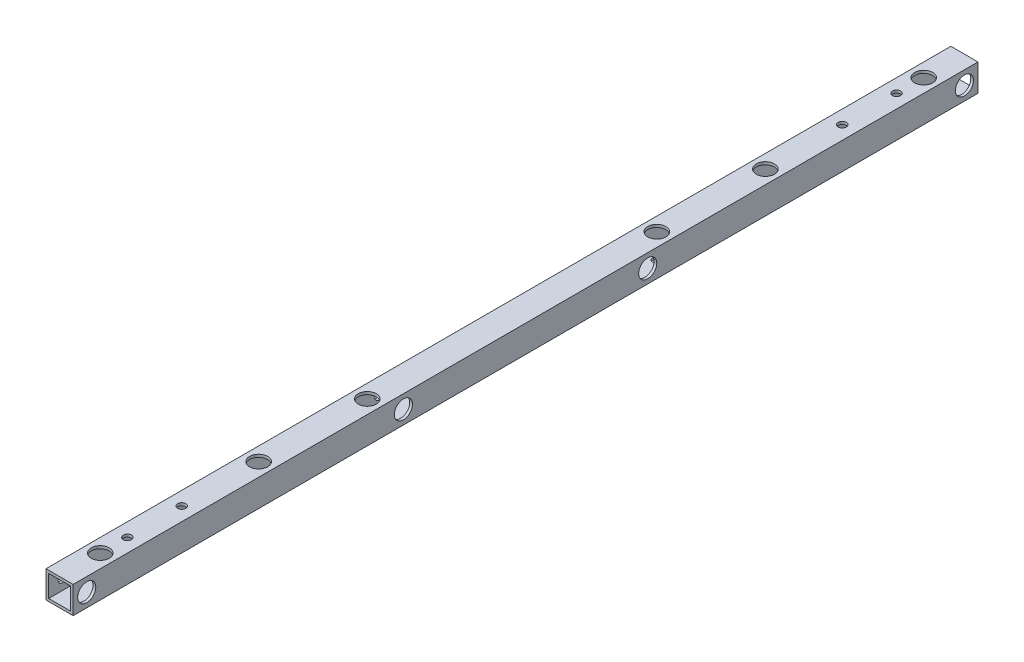
from build123d import *

# Parameters (mm, degrees)
SKETCH_1_W          = 15
SKETCH_1_H          = 15
SKETCH_1_W_2        = 12
SKETCH_1_H_2        = 12
EXTRUDE_1_DEPTH     = 500
SKETCH_2_R          = 2.25
CUT_EXTRUDE_1_DEPTH = 25
SKETCH_3_R          = 2.25
CUT_EXTRUDE_2_DEPTH = 25
SKETCH_4_R          = 2.25
CUT_EXTRUDE_3_DEPTH = 20
SKETCH_5_R          = 5
CUT_EXTRUDE_4_DEPTH = 10
SKETCH_6_R          = 5
CUT_EXTRUDE_5_DEPTH = 10


with BuildPart() as part:
    # ｽｹｯﾁ1 → ﾎﾞｽ - 押し出し1 (new body)
    with BuildSketch(Plane.XY):
        Rectangle(SKETCH_1_W, SKETCH_1_H)
        Rectangle(SKETCH_1_W_2, SKETCH_1_H_2, mode=Mode.SUBTRACT)
    extrude(amount=EXTRUDE_1_DEPTH)

    # ｽｹｯﾁ2 → ｶｯﾄ - 押し出し1 (cut)
    with BuildSketch(Plane(origin=(7.5, 0, 0), x_dir=(0, 0, -1), z_dir=(1, 0, 0))):
        with Locations((-492.5, 0)):
            Circle(SKETCH_2_R)
        with Locations((-7.5, 0)):
            Circle(SKETCH_2_R)
        with Locations((-317.5, 0)):
            Circle(SKETCH_2_R)
        with Locations((-182.5, 0)):
            Circle(SKETCH_2_R)
    extrude(amount=-CUT_EXTRUDE_1_DEPTH, mode=Mode.SUBTRACT)

    # ｽｹｯﾁ3 → ｶｯﾄ - 押し出し2 (cut)
    with BuildSketch(Plane(origin=(0, 7.5, 0), x_dir=(1, 0, 0), z_dir=(0, 1, 0))):
        with Locations((0, -22.5)):
            Circle(SKETCH_3_R)
        with Locations((0, -477.5)):
            Circle(SKETCH_3_R)
        with Locations((0, -37.5)):
            Circle(SKETCH_3_R)
        with Locations((0, -462.5)):
            Circle(SKETCH_3_R)
        with Locations((0, -67.5)):
            Circle(SKETCH_3_R)
        with Locations((0, -432.5)):
            Circle(SKETCH_3_R)
    extrude(amount=-CUT_EXTRUDE_2_DEPTH, mode=Mode.SUBTRACT)

    # ｽｹｯﾁ4 → ｶｯﾄ - 押し出し3 (cut)
    with BuildSketch(Plane(origin=(0, -7.5, 0), x_dir=(-1, 0, 0), z_dir=(0, -1, 0))):
        with Locations((0, -390)):
            Circle(SKETCH_4_R)
        with Locations((0, -330)):
            Circle(SKETCH_4_R)
        with Locations((0, -110)):
            Circle(SKETCH_4_R)
        with Locations((0, -170)):
            Circle(SKETCH_4_R)
    extrude(amount=-CUT_EXTRUDE_3_DEPTH, mode=Mode.SUBTRACT)

    # ｽｹｯﾁ5 → ｶｯﾄ - 押し出し4 (cut)
    with BuildSketch(Plane(origin=(0, 7.5, 0), x_dir=(1, 0, 0), z_dir=(0, 1, 0))):
        with Locations((0, -22.5)):
            Circle(SKETCH_5_R)
        with Locations((0, -477.5)):
            Circle(SKETCH_5_R)
        with Locations((0, -390)):
            Circle(SKETCH_5_R)
        with Locations((0, -330)):
            Circle(SKETCH_5_R)
        with Locations((0, -110)):
            Circle(SKETCH_5_R)
        with Locations((0, -170)):
            Circle(SKETCH_5_R)
    extrude(amount=-CUT_EXTRUDE_4_DEPTH, mode=Mode.SUBTRACT)

    # ｽｹｯﾁ6 → ｶｯﾄ - 押し出し5 (cut)
    with BuildSketch(Plane(origin=(7.5, 0, 0), x_dir=(0, 0, -1), z_dir=(1, 0, 0))):
        with Locations((-492.5, 0)):
            Circle(SKETCH_6_R)
        with Locations((-317.5, 0)):
            Circle(SKETCH_6_R)
        with Locations((-182.5, 0)):
            Circle(SKETCH_6_R)
        with Locations((-7.5, 0)):
            Circle(SKETCH_6_R)
    extrude(amount=-CUT_EXTRUDE_5_DEPTH, mode=Mode.SUBTRACT)


solid = part.part
